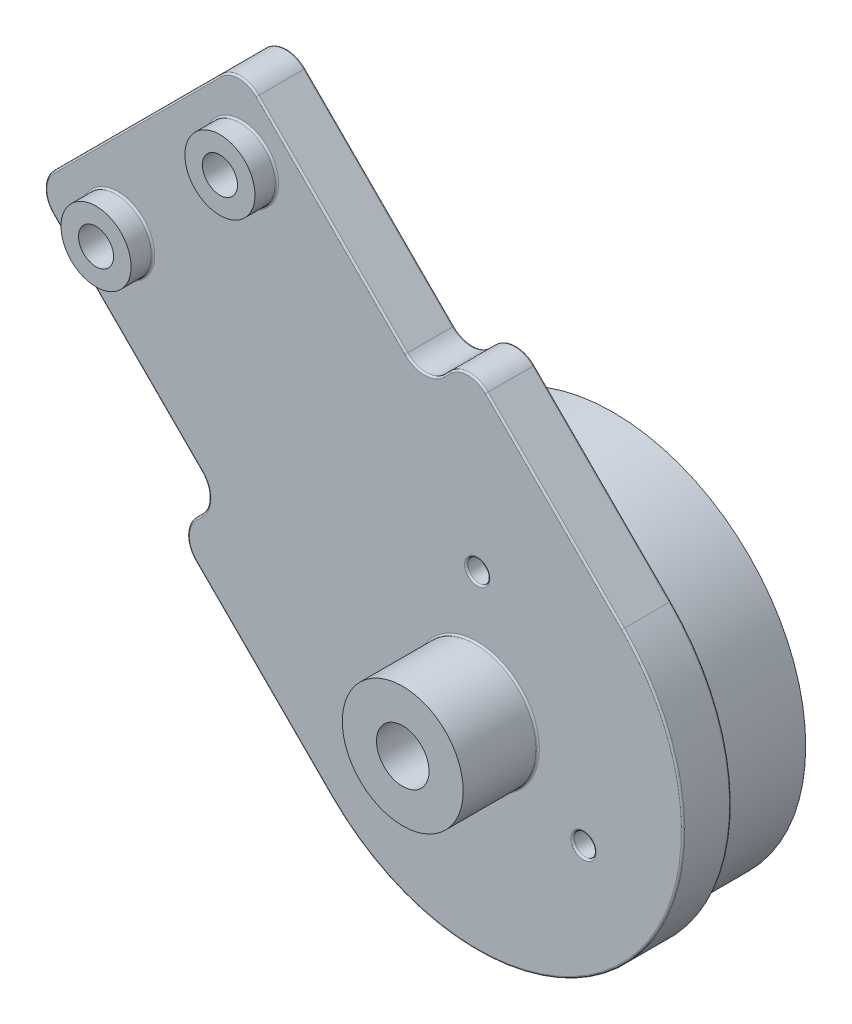
from build123d import *

# Parameters (mm, degrees)
SKETCH5_R           = 10
SKETCH5_R_2         = 1
BOSS_EXTRUDE1_DEPTH = 2.75
SKETCH6_R           = 10
BOSS_EXTRUDE2_DEPTH = 1
SKETCH7_R           = 11
SKETCH7_R_2         = 10
BOSS_EXTRUDE3_DEPTH = 5
FILLET1_R           = 1.5
SKETCH8_R           = 2
SKETCH8_R_2         = 1
BOSS_EXTRUDE4_DEPTH = 1.25
SKETCH9_R           = 1.5
CUT_EXTRUDE1_DEPTH  = 8.75
SKETCH10_R          = 3.45
SKETCH10_R_2        = 1.5
BOSS_EXTRUDE5_DEPTH = 4.25
SKETCH11_R          = 0.625
CUT_EXTRUDE2_DEPTH  = 8.75
FILLET2_R           = 0.1


with BuildPart() as part:
    # Sketch5 → Boss-Extrude1 (new body)
    with BuildSketch(Plane.XY):
        with BuildLine():
            Line((74.720932573, 13.611805538), (86.388194462, 25.279067427))
            Line((86.388194462, 25.279067427), (96.99479618, 14.67246571))
            Line((96.99479618, 14.67246571), (99.469669914, 17.147339444))
            Line((99.469669914, 17.147339444), (108.308504679, 8.308504679))
            ThreePointArc((108.308504679, 8.308504679), (108.308504679, -8.308504679), (91.691495321, -8.308504679))
            Line((91.691495321, -8.308504679), (82.852660556, 0.530330086))
            Line((82.852660556, 0.530330086), (85.32753429, 3.00520382))
            Line((85.32753429, 3.00520382), (74.720932573, 13.611805538))
        make_face()
        with Locations((100, 0)):
            Circle(SKETCH5_R, mode=Mode.SUBTRACT)
        with Locations((79.493903346, 13.435028843)):
            Circle(SKETCH5_R_2, mode=Mode.SUBTRACT)
        with Locations((86.564971157, 20.506096654)):
            Circle(SKETCH5_R_2, mode=Mode.SUBTRACT)
    extrude(amount=BOSS_EXTRUDE1_DEPTH)

    # Sketch6 → Boss-Extrude2 (add)
    with BuildSketch(Plane.XY.offset(2.75)):
        with Locations((100, 0)):
            Circle(SKETCH6_R)
    extrude(amount=-BOSS_EXTRUDE2_DEPTH)

    # Sketch7 → Boss-Extrude3 (add)
    with BuildSketch(Plane(origin=(0, 0, 0), x_dir=(-1, 0, 0), z_dir=(0, 0, -1))):
        with Locations((-100, 0)):
            Circle(SKETCH7_R)
        with Locations((-100, 0)):
            Circle(SKETCH7_R_2, mode=Mode.SUBTRACT)
    extrude(amount=BOSS_EXTRUDE3_DEPTH)

    # Fillet1
    fillet1_edges = [part.edges().sort_by_distance(p)[0] for p in [
        (96.99479618, 14.67246571, 1.375),
        (99.469669914, 17.147339444, 1.375),
        (82.852660556, 0.530330086, 1.375),
        (85.32753429, 3.00520382, 1.375),
        (74.720932573, 13.611805538, 1.375),
        (86.388194462, 25.279067427, 1.375),
    ]]
    fillet(fillet1_edges, radius=FILLET1_R)

    # Sketch8 → Boss-Extrude4 (add)
    with BuildSketch(Plane.XY.offset(2.75)):
        with Locations((86.564971157, 20.506096654)):
            Circle(SKETCH8_R)
        with Locations((86.564971157, 20.506096654)):
            Circle(SKETCH8_R_2, mode=Mode.SUBTRACT)
        with Locations((79.493903346, 13.435028843)):
            Circle(SKETCH8_R)
        with Locations((79.493903346, 13.435028843)):
            Circle(SKETCH8_R_2, mode=Mode.SUBTRACT)
    extrude(amount=BOSS_EXTRUDE4_DEPTH)

    # Sketch9 → Cut-Extrude1 (cut, through all)
    with BuildSketch(Plane.XY.offset(2.75)):
        with Locations((100, 0)):
            Circle(SKETCH9_R)
    extrude(amount=-CUT_EXTRUDE1_DEPTH, mode=Mode.SUBTRACT)

    # Sketch10 → Boss-Extrude5 (add)
    with BuildSketch(Plane.XY.offset(2.75)):
        with Locations((100, 0)):
            Circle(SKETCH10_R)
        with Locations((100, 0)):
            Circle(SKETCH10_R_2, mode=Mode.SUBTRACT)
    extrude(amount=BOSS_EXTRUDE5_DEPTH)

    # Sketch11 → Cut-Extrude2 (cut, through all)
    with BuildSketch(Plane.XY.offset(2.75)):
        with Locations((100, 7)):
            Circle(SKETCH11_R)
        with Locations((106.062177826, -3.5)):
            Circle(SKETCH11_R)
        with Locations((93.937822174, -3.5)):
            Circle(SKETCH11_R)
    extrude(amount=-CUT_EXTRUDE2_DEPTH, mode=Mode.SUBTRACT)

    # Fillet2
    fillet2_edges = [part.edges().sort_by_distance(p)[0] for p in [
        (98.5, 0, 1.75),
        (96.55, 0, 2.75),
        (99.375, 7, 1.75),
        (99.375, 7, 2.75),
        (105.437177826, -3.5, 1.75),
        (105.437177826, -3.5, 2.75),
        (93.312822174, -3.5, 1.75),
        (93.312822174, -3.5, 2.75),
        (108.308504679, -8.308504679, 2.75),
        (104.419417382, 12.197591975, 2.75),
        (78.493903346, 13.435028843, 0),
        (85.564971157, 20.506096654, 0),
        (90, 0, 1.75),
        (111, 0, 0),
        (91.691495321, 19.975766569, 0),
        (91.691495321, 19.975766569, 2.75),
        (98.232233047, 15.909902577, 0),
        (98.232233047, 15.909902577, 2.75),
        (87.802408025, -4.419417382, 0),
        (84.090097423, 1.767766953, 0),
        (80.024233431, 8.308504679, 0),
        (80.554563517, 19.445436483, 0),
        (86.388194462, 24.657747084, 0),
        (75.342252916, 13.611805538, 0),
        (83.4739809, 0.530330086, 0),
        (99.469669914, 16.5260191, 0),
        (80.554563517, 19.445436483, 2.75),
        (80.024233431, 8.308504679, 2.75),
        (84.090097423, 1.767766953, 2.75),
        (87.802408025, -4.419417382, 2.75),
        (86.388194462, 24.657747084, 2.75),
        (75.342252916, 13.611805538, 2.75),
        (83.4739809, 0.530330086, 2.75),
        (99.469669914, 16.5260191, 2.75),
        (96.99479618, 15.293786053, 0),
        (96.99479618, 15.293786053, 2.75),
        (84.706213947, 3.00520382, 0),
        (84.706213947, 3.00520382, 2.75),
        (104.419417382, 12.197591975, 0),
        (108.308504679, -8.308504679, 0),
        (84.564971157, 20.506096654, 2.75),
        (77.493903346, 13.435028843, 2.75),
    ]]
    fillet(fillet2_edges, radius=FILLET2_R)


solid = part.part
